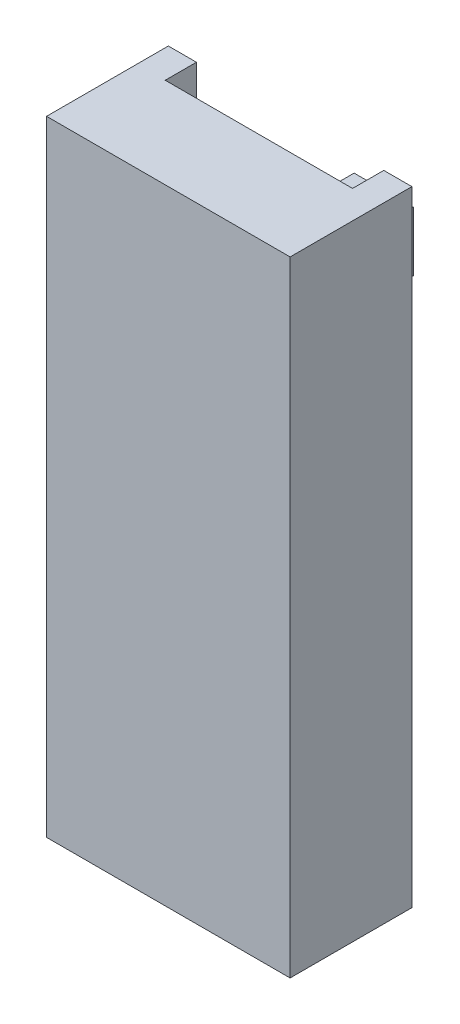
from build123d import *

# Parameters (mm, degrees)
SKETCH1_W           = 7.8
SKETCH1_H           = 3.9
BOSS_EXTRUDE1_DEPTH = 20
CUT_EXTRUDE1_DEPTH  = 15
SKETCH4_W           = 6
SKETCH4_H           = 1
CUT_EXTRUDE2_DEPTH  = 2
SKETCH6_W           = 1.9
SKETCH6_H           = 1.9
BOSS_EXTRUDE3_DEPTH = 2
SKETCH7_W           = 2
SKETCH7_H           = 2
CUT_EXTRUDE3_DEPTH  = 2


with BuildPart() as part:
    # Sketch1 → Boss-Extrude1 (new body)
    with BuildSketch(Plane(origin=(0, 0, 0), x_dir=(1, 0, 0), z_dir=(0, 1, 0))):
        with Locations((1.261259263, 0.247513191)):
            Rectangle(SKETCH1_W, SKETCH1_H)
    extrude(amount=BOSS_EXTRUDE1_DEPTH)

    # Sketch3 → Cut-Extrude1 (cut)
    with BuildSketch(Plane.XZ):
        with BuildLine():
            Line((-0.238740737, -2.197513191), (2.761259263, -2.197513191))
            ThreePointArc((2.761259263, -2.197513191), (2.710148003, -1.809284623), (2.560297369, -1.447513191))
            Line((2.560297369, -1.447513191), (-0.037778842, -1.447513191))
            ThreePointArc((-0.037778842, -1.447513191), (-0.187629476, -1.809284623), (-0.238740737, -2.197513191))
        make_face()
        with BuildLine():
            Line((2.761259263, -2.197513191), (4.261259263, -2.197513191))
            Line((4.261259263, -2.197513191), (4.261259263, -1.447513191))
            Line((4.261259263, -1.447513191), (2.560297369, -1.447513191))
            ThreePointArc((2.560297369, -1.447513191), (2.710148003, -1.809284623), (2.761259263, -2.197513191))
        make_face()
        with BuildLine():
            Line((-0.037778842, -1.447513191), (2.560297369, -1.447513191))
            ThreePointArc((2.560297369, -1.447513191), (1.261259263, -0.697513191), (-0.037778842, -1.447513191))
        make_face()
        with BuildLine():
            Line((-1.738740737, -2.197513191), (-0.238740737, -2.197513191))
            ThreePointArc((-0.238740737, -2.197513191), (-0.187629476, -1.809284623), (-0.037778842, -1.447513191))
            Line((-0.037778842, -1.447513191), (-1.738740737, -1.447513191))
            Line((-1.738740737, -1.447513191), (-1.738740737, -2.197513191))
        make_face()
    extrude(amount=-CUT_EXTRUDE1_DEPTH, mode=Mode.SUBTRACT)

    # Sketch4 → Cut-Extrude2 (cut)
    with BuildSketch(Plane(origin=(0, 20, 0), x_dir=(1, 0, 0), z_dir=(0, 1, 0))):
        with Locations((1.261259263, 1.697513191)):
            Rectangle(SKETCH4_W, SKETCH4_H)
    extrude(amount=-CUT_EXTRUDE2_DEPTH, mode=Mode.SUBTRACT)

    # Sketch6 → Boss-Extrude3 (add)
    with BuildSketch(Plane(origin=(0, 0, -2.197513191), x_dir=(-1, 0, 0), z_dir=(0, 0, -1))):
        with Locations((-2.261259263, 16.5)):
            Rectangle(SKETCH6_W, SKETCH6_H)
    extrude(amount=BOSS_EXTRUDE3_DEPTH)

    # Sketch7 → Cut-Extrude3 (cut)
    with BuildSketch(Plane(origin=(0, 0, -2.197513191), x_dir=(-1, 0, 0), z_dir=(0, 0, -1))):
        with Locations((-0.261259263, 16.5)):
            Rectangle(SKETCH7_W, SKETCH7_H)
    extrude(amount=-CUT_EXTRUDE3_DEPTH, mode=Mode.SUBTRACT)


solid = part.part
